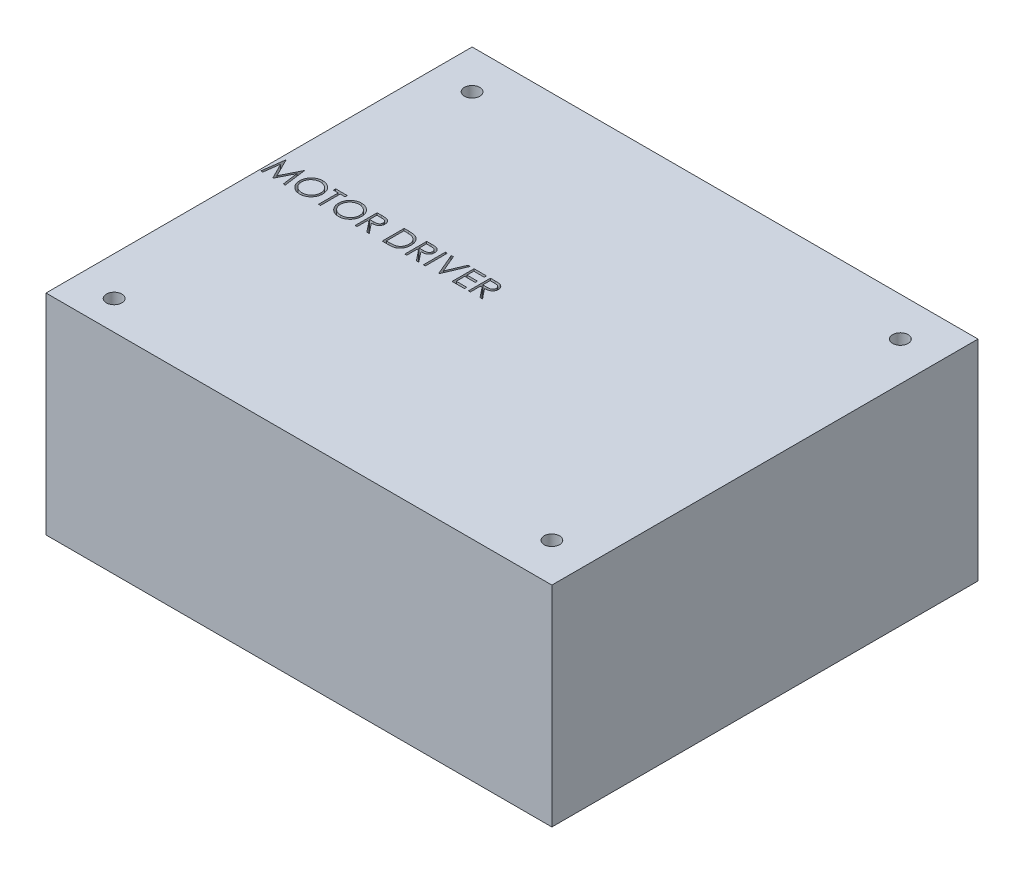
from build123d import *

# Parameters (mm, degrees)
SKETCH1_W           = 80.56
SKETCH1_H           = 67.86
BOSS_EXTRUDE1_DEPTH = 33.37
SKETCH2_R           = 1.23
CUT_EXTRUDE1_DEPTH  = 34.37
SKETCH3_W           = 0.314102564
SKETCH3_H           = 3.5
CUT_EXTRUDE2_DEPTH  = 34.37


with BuildPart() as part:
    # Sketch1 → Boss-Extrude1 (new body)
    with BuildSketch(Plane(origin=(0, 0, 0), x_dir=(1, 0, 0), z_dir=(0, 1, 0))):
        with Locations((40.28, 33.93)):
            Rectangle(SKETCH1_W, SKETCH1_H)
    extrude(amount=BOSS_EXTRUDE1_DEPTH)

    # Sketch2 → Cut-Extrude1 (cut, through all)
    with BuildSketch(Plane(origin=(0, 33.37, 0), x_dir=(1, 0, 0), z_dir=(0, 1, 0))):
        with Locations((6.18, 61.68)):
            Circle(SKETCH2_R)
        with Locations((6.18, 4.670315746)):
            Circle(SKETCH2_R)
        with Locations((74.38, 6.18)):
            Circle(SKETCH2_R)
        with Locations((74.38, 61.68)):
            Circle(SKETCH2_R)
    extrude(amount=-CUT_EXTRUDE1_DEPTH, mode=Mode.SUBTRACT)

    # Sketch3 → Cut-Extrude2 (cut, through all)
    with BuildSketch(Plane(origin=(0, 33.37, 0), x_dir=(1, 0, 0), z_dir=(0, 1, 0))):
        Polygon((0.269230769, 33.93), (0.731270032, 37.43), (0.776141827, 37.43), (2.221153846, 34.558205128), (3.661959135, 37.43), (3.706830929, 37.43), (4.173076923, 33.93), (3.858974359, 33.93), (3.522435897, 36.446326122), (2.259715545, 33.93), (2.188201122, 33.93), (0.919871795, 36.454038462), (0.585436699, 33.93), align=None)
        with BuildLine():
            add(Edge.make_bspline(
                [(6.528846154, 37.51974359), (6.59365426, 37.51810211), (6.720942727, 37.514878109), (6.908017624, 37.490199006), (7.08661272, 37.447503616), (7.258182859, 37.390640633), (7.420675835, 37.314786248), (7.575314728, 37.2231011), (7.721731601, 37.114624641), (7.857952983, 36.990195414), (7.982609933, 36.85481196), (8.092435819, 36.71033405), (8.184478113, 36.557635248), (8.2600639, 36.397174417), (8.31936251, 36.229314449), (8.360281554, 36.053160446), (8.386419704, 35.869853756), (8.389475481, 35.744826892), (8.391025641, 35.681402244)],
                knots=[0, 0, 0, 0, 0.000194393, 0.000381804, 0.00056479, 0.000744601, 0.000923091, 0.001101652, 0.001283106, 0.001468738, 0.001654324, 0.001834514, 0.002012231, 0.002188181, 0.002365797, 0.002545211, 0.002729936, 0.002920126, 0.002920126, 0.002920126, 0.002920126], degree=3))
            add(Edge.make_bspline(
                [(8.391025641, 35.681402244), (8.389475709, 35.618444797), (8.386420612, 35.494348377), (8.360251834, 35.312204933), (8.319210834, 35.137114236), (8.260614568, 34.969368583), (8.18538909, 34.80879102), (8.092733919, 34.655804066), (7.983592708, 34.510357567), (7.859385857, 34.374044902), (7.723984815, 34.249047431), (7.578754548, 34.140128556), (7.426961228, 34.046404431), (7.26665152, 33.971620757), (7.099951483, 33.911848837), (6.92536916, 33.871096207), (6.743722606, 33.844809163), (6.619851602, 33.841790647), (6.556891026, 33.84025641)],
                knots=[0, 0, 0, 0, 0.000188789, 0.000372126, 0.000550857, 0.00072758, 0.000904164, 0.001081881, 0.001263191, 0.001448823, 0.00163441, 0.001815159, 0.001992641, 0.002168591, 0.002344885, 0.002522934, 0.002705576, 0.002894365, 0.002894365, 0.002894365, 0.002894365], degree=3))
            add(Edge.make_bspline(
                [(6.556891026, 33.84025641), (6.493466707, 33.841805797), (6.368440491, 33.844860051), (6.184903455, 33.871041456), (6.008625711, 33.91198276), (5.84011136, 33.970492196), (5.679266431, 34.046109427), (5.525776348, 34.138313806), (5.380257201, 34.247720947), (5.243915454, 34.371887521), (5.119166256, 34.507059073), (5.01040688, 34.651893329), (4.918181767, 34.803548785), (4.842818435, 34.962446309), (4.783153975, 35.127817752), (4.742449157, 35.300766229), (4.716113205, 35.480305735), (4.713078359, 35.602548634), (4.711538462, 35.664575321)],
                knots=[0, 0, 0, 0, 0.00019019, 0.000374915, 0.000555011, 0.000732396, 0.00090898, 0.001087298, 0.001268608, 0.00145424, 0.001639827, 0.001819595, 0.001996712, 0.002171394, 0.002346367, 0.002523053, 0.002703612, 0.002889599, 0.002889599, 0.002889599, 0.002889599], degree=3))
            add(Edge.make_bspline(
                [(4.711538462, 35.664575321), (4.712073097, 35.70620799), (4.713135623, 35.788948113), (4.725927316, 35.911814713), (4.744489017, 36.032705371), (4.77109093, 36.151276319), (4.805882597, 36.267237304), (4.846934624, 36.381388067), (4.897074469, 36.49257179), (4.953755117, 36.601315182), (5.017016925, 36.705923088), (5.086892675, 36.804802671), (5.160928043, 36.898783668), (5.242091437, 36.985430672), (5.327707882, 37.067264328), (5.41916626, 37.143027045), (5.515908505, 37.213401996), (5.618350884, 37.276822337), (5.723969159, 37.334181472), (5.832845937, 37.383403323), (5.943502509, 37.425649384), (6.056457157, 37.459890209), (6.171409929, 37.486922245), (6.288611713, 37.505329599), (6.407969139, 37.518153917), (6.488380458, 37.519211419), (6.528846154, 37.51974359)],
                knots=[0, 0, 0, 0, 0.000124849, 0.000248123, 0.000370193, 0.00049164, 0.000612319, 0.000733199, 0.000855287, 0.000977905, 0.001100913, 0.001221706, 0.001340948, 0.001459521, 0.001577551, 0.001696047, 0.001815534, 0.001936153, 0.002057243, 0.002175846, 0.002294342, 0.002412335, 0.002529682, 0.00264829, 0.002768075, 0.00288942, 0.00288942, 0.00288942, 0.00288942], degree=3))
        make_face()
        with BuildLine():
            add(Edge.make_bspline(
                [(6.544270833, 37.160769231), (6.5110562, 37.160364341), (6.444944467, 37.159558431), (6.346659931, 37.148942715), (6.249667997, 37.133812826), (6.153948635, 37.112231305), (6.059902345, 37.082827253), (5.966652504, 37.048986345), (5.87504945, 37.007765254), (5.785395592, 36.96119255), (5.698480517, 36.909643629), (5.616467816, 36.852671862), (5.539145172, 36.791613307), (5.466701905, 36.72632547), (5.399350733, 36.656475868), (5.335766031, 36.583123432), (5.27849645, 36.504171541), (5.226010873, 36.421761134), (5.179043033, 36.335999553), (5.137277678, 36.247789691), (5.103113669, 36.156412004), (5.075251293, 36.062857846), (5.052151482, 35.967275387), (5.037517558, 35.868939538), (5.026785199, 35.768344426), (5.026025353, 35.700362572), (5.025641026, 35.665977564)],
                knots=[0, 0, 0, 0, 9.9599e-05, 0.000198245, 0.000296222, 0.00039402, 0.00049227, 0.000591646, 0.000691452, 0.000793368, 0.000894612, 0.000994383, 0.001092713, 0.00119001, 0.001286696, 0.001383657, 0.001480979, 0.001579008, 0.001676595, 0.001774142, 0.001871547, 0.001968922, 0.002066879, 0.00216624, 0.00226698, 0.002370083, 0.002370083, 0.002370083, 0.002370083], degree=3))
            add(Edge.make_bspline(
                [(5.025641026, 35.665977564), (5.026915888, 35.615415343), (5.029423935, 35.515943813), (5.051381506, 35.370175669), (5.08520348, 35.230087383), (5.135060846, 35.096445474), (5.197411461, 34.968101191), (5.274438351, 34.846193086), (5.365697437, 34.730688212), (5.469360964, 34.622392943), (5.58268367, 34.523547138), (5.7030164, 34.43678373), (5.829070008, 34.36337348), (5.96117321, 34.303568408), (6.098620749, 34.25617867), (6.2422983, 34.223700039), (6.39124876, 34.202324583), (6.492779415, 34.200271827), (6.544270833, 34.199230769)],
                knots=[0, 0, 0, 0, 0.000151605, 0.000298253, 0.000441263, 0.000583229, 0.000725274, 0.000868635, 0.001014928, 0.001166177, 0.001317744, 0.00146543, 0.001610576, 0.001754594, 0.001899821, 0.002045914, 0.002195936, 0.002350312, 0.002350312, 0.002350312, 0.002350312], degree=3))
            add(Edge.make_bspline(
                [(6.544270833, 34.199230769), (6.578880335, 34.199706274), (6.647521371, 34.200649342), (6.749616894, 34.210148018), (6.849873105, 34.225379888), (6.948149385, 34.247310543), (7.044334197, 34.27475775), (7.138829, 34.307365478), (7.23062729, 34.348046682), (7.320887128, 34.392994633), (7.40728337, 34.444234791), (7.489758902, 34.49927294), (7.566234882, 34.560241561), (7.638623953, 34.624559374), (7.706251642, 34.693523221), (7.768660626, 34.767043443), (7.825640759, 34.8455841), (7.878106405, 34.927869506), (7.924909668, 35.013865759), (7.965688767, 35.102395437), (8.000284883, 35.193240546), (8.028213388, 35.286532118), (8.050098849, 35.382092966), (8.065178769, 35.480051045), (8.075727208, 35.580210387), (8.076522285, 35.647954243), (8.076923077, 35.682103365)],
                knots=[0, 0, 0, 0, 0.000103804, 0.000205874, 0.000307314, 0.000407849, 0.000507719, 0.000607281, 0.000707445, 0.000808723, 0.000909609, 0.001008589, 0.001105934, 0.001202762, 0.001298946, 0.001395452, 0.001491794, 0.001589823, 0.001688026, 0.001785277, 0.001882027, 0.001979402, 0.0020772, 0.002175869, 0.002276609, 0.002379011, 0.002379011, 0.002379011, 0.002379011], degree=3))
            add(Edge.make_bspline(
                [(8.076923077, 35.682103365), (8.076521964, 35.71601887), (8.075726282, 35.78329652), (8.065183808, 35.882757338), (8.050082917, 35.98001055), (8.028320209, 36.074674353), (8.000270056, 36.166772878), (7.965682725, 36.256219625), (7.924897426, 36.343347821), (7.878089201, 36.427942118), (7.825473378, 36.509116855), (7.767979135, 36.586719268), (7.704613787, 36.659292009), (7.637187762, 36.728626703), (7.564016876, 36.793244593), (7.485432582, 36.853167114), (7.402388904, 36.909840388), (7.314461669, 36.96096595), (7.223717715, 37.008180182), (7.130603757, 37.048631186), (7.036174658, 37.083003305), (6.940670545, 37.11232027), (6.843287567, 37.1337283), (6.744683738, 37.14895635), (6.64499548, 37.159554736), (6.57795226, 37.160363114), (6.544270833, 37.160769231)],
                knots=[0, 0, 0, 0, 0.000101701, 0.000201743, 0.00029972, 0.000396835, 0.000492868, 0.000588308, 0.000684288, 0.000781261, 0.000878109, 0.000974304, 0.001070733, 0.001166917, 0.001264269, 0.001363274, 0.001463228, 0.001565678, 0.001668217, 0.001769947, 0.001869982, 0.001969573, 0.002069423, 0.002168785, 0.002268827, 0.002369827, 0.002369827, 0.002369827, 0.002369827], degree=3))
        make_face(mode=Mode.SUBTRACT)
        Polygon((8.705128205, 37.071025641), (8.705128205, 37.43), (10.544871795, 37.43), (10.544871795, 37.071025641), (9.782051282, 37.071025641), (9.782051282, 33.93), (9.467948718, 33.93), (9.467948718, 37.071025641), align=None)
        with BuildLine():
            add(Edge.make_bspline(
                [(12.721153846, 37.51974359), (12.785961952, 37.51810211), (12.913250419, 37.514878109), (13.100325317, 37.490199006), (13.278920412, 37.447503616), (13.450490551, 37.390640633), (13.612983527, 37.314786248), (13.76762242, 37.2231011), (13.914039294, 37.114624641), (14.050260675, 36.990195414), (14.174917626, 36.85481196), (14.284743512, 36.71033405), (14.376785806, 36.557635248), (14.452371593, 36.397174417), (14.511670202, 36.229314449), (14.552589246, 36.053160446), (14.578727396, 35.869853756), (14.581783174, 35.744826892), (14.583333333, 35.681402244)],
                knots=[0, 0, 0, 0, 0.000194393, 0.000381804, 0.00056479, 0.000744601, 0.000923091, 0.001101652, 0.001283106, 0.001468738, 0.001654324, 0.001834514, 0.002012231, 0.002188181, 0.002365797, 0.002545211, 0.002729936, 0.002920126, 0.002920126, 0.002920126, 0.002920126], degree=3))
            add(Edge.make_bspline(
                [(14.583333333, 35.681402244), (14.581783401, 35.618444797), (14.578728304, 35.494348377), (14.552559527, 35.312204933), (14.511518527, 35.137114236), (14.452922261, 34.969368583), (14.377696782, 34.80879102), (14.285041611, 34.655804066), (14.1759004, 34.510357567), (14.051693549, 34.374044902), (13.916292507, 34.249047431), (13.77106224, 34.140128556), (13.61926892, 34.046404431), (13.458959212, 33.971620757), (13.292259175, 33.911848837), (13.117676852, 33.871096207), (12.936030298, 33.844809163), (12.812159295, 33.841790647), (12.749198718, 33.84025641)],
                knots=[0, 0, 0, 0, 0.000188789, 0.000372126, 0.000550857, 0.00072758, 0.000904164, 0.001081881, 0.001263191, 0.001448823, 0.00163441, 0.001815159, 0.001992641, 0.002168591, 0.002344885, 0.002522934, 0.002705576, 0.002894365, 0.002894365, 0.002894365, 0.002894365], degree=3))
            add(Edge.make_bspline(
                [(12.749198718, 33.84025641), (12.685774399, 33.841805797), (12.560748183, 33.844860051), (12.377211148, 33.871041456), (12.200933404, 33.91198276), (12.032419053, 33.970492196), (11.871574123, 34.046109427), (11.71808404, 34.138313806), (11.572564893, 34.247720947), (11.436223147, 34.371887521), (11.311473948, 34.507059073), (11.202714573, 34.651893329), (11.110489459, 34.803548785), (11.035126127, 34.962446309), (10.975461668, 35.127817752), (10.934756849, 35.300766229), (10.908420897, 35.480305735), (10.905386051, 35.602548634), (10.903846154, 35.664575321)],
                knots=[0, 0, 0, 0, 0.00019019, 0.000374915, 0.000555011, 0.000732396, 0.00090898, 0.001087298, 0.001268608, 0.00145424, 0.001639827, 0.001819595, 0.001996712, 0.002171394, 0.002346367, 0.002523053, 0.002703612, 0.002889599, 0.002889599, 0.002889599, 0.002889599], degree=3))
            add(Edge.make_bspline(
                [(10.903846154, 35.664575321), (10.904380789, 35.70620799), (10.905443316, 35.788948113), (10.918235008, 35.911814713), (10.936796709, 36.032705371), (10.963398622, 36.151276319), (10.998190289, 36.267237304), (11.039242316, 36.381388067), (11.089382162, 36.49257179), (11.14606281, 36.601315182), (11.209324618, 36.705923088), (11.279200367, 36.804802671), (11.353235736, 36.898783668), (11.434399129, 36.985430672), (11.520015574, 37.067264328), (11.611473953, 37.143027045), (11.708216197, 37.213401996), (11.810658577, 37.276822337), (11.916276852, 37.334181472), (12.025153629, 37.383403323), (12.135810201, 37.425649384), (12.248764849, 37.459890209), (12.363717621, 37.486922245), (12.480919405, 37.505329599), (12.600276832, 37.518153917), (12.680688151, 37.519211419), (12.721153846, 37.51974359)],
                knots=[0, 0, 0, 0, 0.000124849, 0.000248123, 0.000370193, 0.00049164, 0.000612319, 0.000733199, 0.000855287, 0.000977905, 0.001100913, 0.001221706, 0.001340948, 0.001459521, 0.001577551, 0.001696047, 0.001815534, 0.001936153, 0.002057243, 0.002175846, 0.002294342, 0.002412335, 0.002529682, 0.00264829, 0.002768075, 0.00288942, 0.00288942, 0.00288942, 0.00288942], degree=3))
        make_face()
        with BuildLine():
            add(Edge.make_bspline(
                [(12.736578526, 37.160769231), (12.703363892, 37.160364341), (12.637252159, 37.159558431), (12.538967623, 37.148942715), (12.441975689, 37.133812826), (12.346256327, 37.112231305), (12.252210038, 37.082827253), (12.158960196, 37.048986345), (12.067357142, 37.007765254), (11.977703285, 36.96119255), (11.890788209, 36.909643629), (11.808775508, 36.852671862), (11.731452864, 36.791613307), (11.659009597, 36.72632547), (11.591658425, 36.656475868), (11.528073724, 36.583123432), (11.470804142, 36.504171541), (11.418318565, 36.421761134), (11.371350725, 36.335999553), (11.32958537, 36.247789691), (11.295421362, 36.156412004), (11.267558985, 36.062857846), (11.244459174, 35.967275387), (11.22982525, 35.868939538), (11.219092891, 35.768344426), (11.218333045, 35.700362572), (11.217948718, 35.665977564)],
                knots=[0, 0, 0, 0, 9.9599e-05, 0.000198245, 0.000296222, 0.00039402, 0.00049227, 0.000591646, 0.000691452, 0.000793368, 0.000894612, 0.000994383, 0.001092713, 0.00119001, 0.001286696, 0.001383657, 0.001480979, 0.001579008, 0.001676595, 0.001774142, 0.001871547, 0.001968922, 0.002066879, 0.00216624, 0.00226698, 0.002370083, 0.002370083, 0.002370083, 0.002370083], degree=3))
            add(Edge.make_bspline(
                [(11.217948718, 35.665977564), (11.21922358, 35.615415343), (11.221731628, 35.515943813), (11.243689198, 35.370175669), (11.277511172, 35.230087383), (11.327368539, 35.096445474), (11.389719153, 34.968101191), (11.466746044, 34.846193086), (11.558005129, 34.730688212), (11.661668656, 34.622392943), (11.774991362, 34.523547138), (11.895324092, 34.43678373), (12.0213777, 34.36337348), (12.153480903, 34.303568408), (12.290928442, 34.25617867), (12.434605993, 34.223700039), (12.583556452, 34.202324583), (12.685087107, 34.200271827), (12.736578526, 34.199230769)],
                knots=[0, 0, 0, 0, 0.000151605, 0.000298253, 0.000441263, 0.000583229, 0.000725274, 0.000868635, 0.001014928, 0.001166177, 0.001317744, 0.00146543, 0.001610576, 0.001754594, 0.001899821, 0.002045914, 0.002195936, 0.002350312, 0.002350312, 0.002350312, 0.002350312], degree=3))
            add(Edge.make_bspline(
                [(12.736578526, 34.199230769), (12.771188027, 34.199706274), (12.839829064, 34.200649342), (12.941924586, 34.210148018), (13.042180798, 34.225379888), (13.140457078, 34.247310543), (13.236641889, 34.27475775), (13.331136692, 34.307365478), (13.422934982, 34.348046682), (13.51319482, 34.392994633), (13.599591062, 34.444234791), (13.682066594, 34.49927294), (13.758542574, 34.560241561), (13.830931645, 34.624559374), (13.898559334, 34.693523221), (13.960968319, 34.767043443), (14.017948451, 34.8455841), (14.070414097, 34.927869506), (14.11721736, 35.013865759), (14.157996459, 35.102395437), (14.192592575, 35.193240546), (14.22052108, 35.286532118), (14.242406542, 35.382092966), (14.257486462, 35.480051045), (14.2680349, 35.580210387), (14.268829977, 35.647954243), (14.269230769, 35.682103365)],
                knots=[0, 0, 0, 0, 0.000103804, 0.000205874, 0.000307314, 0.000407849, 0.000507719, 0.000607281, 0.000707445, 0.000808723, 0.000909609, 0.001008589, 0.001105934, 0.001202762, 0.001298946, 0.001395452, 0.001491794, 0.001589823, 0.001688026, 0.001785277, 0.001882027, 0.001979402, 0.0020772, 0.002175869, 0.002276609, 0.002379011, 0.002379011, 0.002379011, 0.002379011], degree=3))
            add(Edge.make_bspline(
                [(14.269230769, 35.682103365), (14.268829656, 35.71601887), (14.268033975, 35.78329652), (14.2574915, 35.882757338), (14.24239061, 35.98001055), (14.220627902, 36.074674353), (14.192577748, 36.166772878), (14.157990418, 36.256219625), (14.117205118, 36.343347821), (14.070396894, 36.427942118), (14.01778107, 36.509116855), (13.960286827, 36.586719268), (13.896921479, 36.659292009), (13.829495454, 36.728626703), (13.756324569, 36.793244593), (13.677740275, 36.853167114), (13.594696597, 36.909840388), (13.506769361, 36.96096595), (13.416025408, 37.008180182), (13.32291145, 37.048631186), (13.22848235, 37.083003305), (13.132978238, 37.11232027), (13.035595259, 37.1337283), (12.936991431, 37.14895635), (12.837303172, 37.159554736), (12.770259952, 37.160363114), (12.736578526, 37.160769231)],
                knots=[0, 0, 0, 0, 0.000101701, 0.000201743, 0.00029972, 0.000396835, 0.000492868, 0.000588308, 0.000684288, 0.000781261, 0.000878109, 0.000974304, 0.001070733, 0.001166917, 0.001264269, 0.001363274, 0.001463228, 0.001565678, 0.001668217, 0.001769947, 0.001869982, 0.001969573, 0.002069423, 0.002168785, 0.002268827, 0.002369827, 0.002369827, 0.002369827, 0.002369827], degree=3))
        make_face(mode=Mode.SUBTRACT)
        with BuildLine():
            Line((15.301282051, 37.43), (16.001702724, 37.43))
            add(Edge.make_bspline(
                [(16.001702724, 37.43), (16.048443853, 37.429844414), (16.138191997, 37.429545672), (16.266765268, 37.427879909), (16.383592365, 37.423105553), (16.488612204, 37.41899697), (16.581822859, 37.411505028), (16.66351015, 37.404344381), (16.733297847, 37.39497072), (16.775543698, 37.386265297), (16.794671474, 37.382323718)],
                knots=[0, 0, 0, 0, 0.000140226, 0.00026925, 0.000385712, 0.000490995, 0.000584507, 0.000666202, 0.000736998, 0.000795574, 0.000795574, 0.000795574, 0.000795574], degree=3))
            add(Edge.make_bspline(
                [(16.794671474, 37.382323718), (16.820278098, 37.375996953), (16.870945088, 37.363478389), (16.943895154, 37.337018788), (17.013409478, 37.306399163), (17.079199302, 37.270435443), (17.140935093, 37.228860663), (17.199253404, 37.182392541), (17.254418868, 37.131285335), (17.304200498, 37.074250494), (17.35113955, 37.014413984), (17.390728176, 36.949710227), (17.424854656, 36.8820487), (17.452025173, 36.810741282), (17.473903146, 36.73647951), (17.489329386, 36.658590713), (17.498580573, 36.577429738), (17.499522429, 36.52207183), (17.5, 36.494002404)],
                knots=[0, 0, 0, 0, 7.9081e-05, 0.000156475, 0.000232432, 0.000306798, 0.00038108, 0.000455429, 0.000530331, 0.000606314, 0.000682321, 0.000758201, 0.000833453, 0.000909362, 0.000986794, 0.001065445, 0.001147284, 0.001231465, 0.001231465, 0.001231465, 0.001231465], degree=3))
            add(Edge.make_bspline(
                [(17.5, 36.494002404), (17.498531002, 36.447367299), (17.495664606, 36.356370131), (17.468939502, 36.22430925), (17.425162983, 36.101119935), (17.364839694, 35.986957297), (17.288020218, 35.884046652), (17.195695427, 35.793656197), (17.087813815, 35.718016284), (16.987384499, 35.665563479), (16.8986703, 35.631970571), (16.825636987, 35.608334212), (16.745970009, 35.590072247), (16.660432675, 35.573712115), (16.568669019, 35.56136042), (16.47089898, 35.552313826), (16.367052828, 35.546659777), (16.295713759, 35.545817772), (16.259014423, 35.545384615)],
                knots=[0, 0, 0, 0, 0.000139777, 0.000272741, 0.000402249, 0.000530843, 0.000658588, 0.000786009, 0.000916741, 0.001052522, 0.001124656, 0.001201155, 0.001282612, 0.001369656, 0.001462366, 0.001560247, 0.001664165, 0.001774261, 0.001774261, 0.001774261, 0.001774261], degree=3))
            Line((16.259014423, 35.545384615), (17.544871795, 33.93))
            Line((17.544871795, 33.93), (17.156450321, 33.93))
            Line((17.156450321, 33.93), (15.870592949, 35.545384615))
            Line((15.870592949, 35.545384615), (15.615384615, 35.545384615))
            Line((15.615384615, 35.545384615), (15.615384615, 33.93))
            Line((15.615384615, 33.93), (15.301282051, 33.93))
            Line((15.301282051, 33.93), (15.301282051, 37.43))
        make_face()
        with BuildLine():
            Line((15.615384615, 37.071025641), (15.615384615, 35.904358974))
            Line((15.615384615, 35.904358974), (16.256209936, 35.899451122))
            add(Edge.make_bspline(
                [(16.256209936, 35.899451122), (16.286129975, 35.899437885), (16.344123532, 35.899412229), (16.428024197, 35.903406005), (16.506144308, 35.907949323), (16.578185061, 35.914898669), (16.644178636, 35.92385474), (16.704092049, 35.935057725), (16.758023101, 35.948109787), (16.820921639, 35.968311413), (16.891158171, 36.000317431), (16.967489631, 36.04688293), (17.032491968, 36.105452049), (17.087409831, 36.172425505), (17.131539262, 36.246061754), (17.162651317, 36.325478123), (17.182393759, 36.408669721), (17.184722304, 36.465847829), (17.185897436, 36.494703526)],
                knots=[0, 0, 0, 0, 8.9746e-05, 0.000173954, 0.000251933, 0.000324488, 0.000391021, 0.000451663, 0.000507268, 0.000557378, 0.000649639, 0.000738152, 0.000824558, 0.000910739, 0.000997194, 0.001080909, 0.00116578, 0.001252248, 0.001252248, 0.001252248, 0.001252248], degree=3))
            add(Edge.make_bspline(
                [(17.185897436, 36.494703526), (17.184695315, 36.522850099), (17.182313149, 36.578626338), (17.162864381, 36.660282248), (17.129975, 36.737349198), (17.085652762, 36.809513683), (17.031653607, 36.875019419), (16.968335794, 36.931066572), (16.897430599, 36.977316037), (16.8311594, 37.006870418), (16.771925188, 37.024990271), (16.720495528, 37.037741435), (16.66238405, 37.047985904), (16.597308592, 37.056193964), (16.525546961, 37.063248909), (16.44673631, 37.068000687), (16.361399529, 37.070814551), (16.302252598, 37.07095364), (16.271634615, 37.071025641)],
                knots=[0, 0, 0, 0, 8.4371e-05, 0.000167192, 0.000250141, 0.000334794, 0.000420435, 0.000503871, 0.000587493, 0.000673488, 0.0007205, 0.000773215, 0.000832351, 0.0008974, 0.000969955, 0.001048634, 0.001134217, 0.001226067, 0.001226067, 0.001226067, 0.001226067], degree=3))
            Line((16.271634615, 37.071025641), (15.615384615, 37.071025641))
        make_face(mode=Mode.SUBTRACT)
        with BuildLine():
            Line((19.608974359, 33.93), (19.608974359, 37.43))
            Line((19.608974359, 37.43), (20.315705128, 37.43))
            add(Edge.make_bspline(
                [(20.315705128, 37.43), (20.377174116, 37.42955743), (20.495931882, 37.428702387), (20.667544329, 37.423280996), (20.826328092, 37.41369053), (20.971760951, 37.399721004), (21.104242163, 37.38256797), (21.223400771, 37.361067566), (21.329852914, 37.335679396), (21.395322354, 37.314033945), (21.426282051, 37.303798077)],
                knots=[0, 0, 0, 0, 0.000184407, 0.000356273, 0.000515031, 0.000661537, 0.000794508, 0.000915664, 0.001024665, 0.001122454, 0.001122454, 0.001122454, 0.001122454], degree=3))
            add(Edge.make_bspline(
                [(21.426282051, 37.303798077), (21.466776791, 37.288367371), (21.546847983, 37.257855877), (21.660855105, 37.200299576), (21.768180468, 37.135086474), (21.869399613, 37.062130611), (21.96220044, 36.979366263), (22.050208336, 36.890309177), (22.12982306, 36.791720837), (22.202731356, 36.685645849), (22.268467016, 36.573333797), (22.325606174, 36.454998688), (22.373060167, 36.33124148), (22.412453393, 36.202406332), (22.443499851, 36.068209954), (22.464681783, 35.928496088), (22.478652773, 35.783816899), (22.480056824, 35.685642435), (22.480769231, 35.635829327)],
                knots=[0, 0, 0, 0, 0.000129935, 0.000256923, 0.000382457, 0.000506429, 0.000630624, 0.000755071, 0.000881654, 0.001010204, 0.001140916, 0.00127168, 0.001403968, 0.001538146, 0.001675568, 0.001816774, 0.001961818, 0.002111216, 0.002111216, 0.002111216, 0.002111216], degree=3))
            add(Edge.make_bspline(
                [(22.480769231, 35.635829327), (22.480140263, 35.592568088), (22.478900817, 35.507317299), (22.467771501, 35.381676404), (22.451595181, 35.259762833), (22.426550983, 35.142157132), (22.39614847, 35.027828915), (22.357184319, 34.91799667), (22.312548823, 34.811652861), (22.260498944, 34.710235385), (22.203357559, 34.614152013), (22.142035816, 34.523576485), (22.07659912, 34.439801263), (22.006423487, 34.362572651), (21.932415771, 34.292007072), (21.85409144, 34.227515057), (21.77124839, 34.170358502), (21.684257667, 34.118291394), (21.590581538, 34.072871038), (21.488445672, 34.034441029), (21.377414494, 34.002594413), (21.257760537, 33.976023517), (21.129277059, 33.954946215), (20.991838093, 33.940819822), (20.845654803, 33.93126689), (20.745275538, 33.930430496), (20.693609776, 33.93)],
                knots=[0, 0, 0, 0, 0.000129755, 0.000255696, 0.000378151, 0.000498469, 0.000616165, 0.000732801, 0.000847787, 0.000961923, 0.00107447, 0.001182981, 0.001289856, 0.001393094, 0.001495748, 0.001596383, 0.00169713, 0.001797413, 0.001900265, 0.002008995, 0.002124372, 0.002246504, 0.002376522, 0.002514729, 0.002660846, 0.00281582, 0.00281582, 0.00281582, 0.00281582], degree=3))
            Line((20.693609776, 33.93), (19.608974359, 33.93))
        make_face()
        with BuildLine():
            Line((19.923076923, 34.288974359), (20.324819712, 34.288974359))
            add(Edge.make_bspline(
                [(20.324819712, 34.288974359), (20.382548082, 34.289222455), (20.493580881, 34.289699636), (20.653238878, 34.293886839), (20.799118274, 34.300728776), (20.931239784, 34.310303854), (21.049528808, 34.322972469), (21.154232558, 34.337097372), (21.245007816, 34.354694823), (21.299937253, 34.370645782), (21.325320513, 34.378016827)],
                knots=[0, 0, 0, 0, 0.000173183, 0.000333094, 0.000479096, 0.000611272, 0.000730431, 0.000835931, 0.000928194, 0.001007458, 0.001007458, 0.001007458, 0.001007458], degree=3))
            add(Edge.make_bspline(
                [(21.325320513, 34.378016827), (21.357268875, 34.389268385), (21.420402513, 34.411502758), (21.511283598, 34.45206042), (21.596040603, 34.500102489), (21.676150628, 34.553504763), (21.750477284, 34.614150765), (21.8199014, 34.680721754), (21.884283201, 34.753556529), (21.942957509, 34.832564691), (21.995465813, 34.917254486), (22.040937043, 35.00679332), (22.080788574, 35.10020013), (22.112067167, 35.198909289), (22.136582751, 35.302038347), (22.153947439, 35.409594561), (22.164762164, 35.521557843), (22.166023612, 35.597709967), (22.166666667, 35.636530449)],
                knots=[0, 0, 0, 0, 0.000101593, 0.000200759, 0.000298073, 0.000393552, 0.000489254, 0.000585454, 0.000681817, 0.000780535, 0.000880346, 0.000980374, 0.001081551, 0.001184655, 0.001290601, 0.001399295, 0.001511268, 0.001627707, 0.001627707, 0.001627707, 0.001627707], degree=3))
            add(Edge.make_bspline(
                [(22.166666667, 35.636530449), (22.166153379, 35.677463929), (22.165145022, 35.757878113), (22.152470711, 35.875868809), (22.133949156, 35.989349459), (22.10716547, 36.098327655), (22.073034591, 36.203016007), (22.030439949, 36.302835517), (21.98177333, 36.398840386), (21.923869993, 36.488814752), (21.8604544, 36.573907861), (21.79007652, 36.651862776), (21.713854482, 36.722857077), (21.632619632, 36.787996389), (21.544082533, 36.844660065), (21.450328842, 36.895346746), (21.349983171, 36.938362638), (21.280170475, 36.9612415), (21.244691506, 36.97286859)],
                knots=[0, 0, 0, 0, 0.000122746, 0.000241136, 0.000355593, 0.000467485, 0.000577457, 0.000685538, 0.00079278, 0.000899951, 0.001006101, 0.00111085, 0.001214524, 0.001318328, 0.001422759, 0.001529413, 0.00163777, 0.001749741, 0.001749741, 0.001749741, 0.001749741], degree=3))
            add(Edge.make_bspline(
                [(21.244691506, 36.97286859), (21.21534036, 36.980985018), (21.15293177, 36.99824277), (21.051092306, 37.017068143), (20.936477156, 37.033672642), (20.808577455, 37.047730681), (20.667538996, 37.057818002), (20.513253308, 37.065389317), (20.345653704, 37.070495949), (20.22947117, 37.070844657), (20.169170673, 37.071025641)],
                knots=[0, 0, 0, 0, 9.1321e-05, 0.000194173, 0.000310382, 0.000438754, 0.000580072, 0.000734511, 0.000902151, 0.001083046, 0.001083046, 0.001083046, 0.001083046], degree=3))
            Line((20.169170673, 37.071025641), (19.923076923, 37.071025641))
            Line((19.923076923, 37.071025641), (19.923076923, 34.288974359))
        make_face(mode=Mode.SUBTRACT)
        with BuildLine():
            Line((23.198717949, 37.43), (23.899138622, 37.43))
            add(Edge.make_bspline(
                [(23.899138622, 37.43), (23.94587975, 37.429844414), (24.035627895, 37.429545672), (24.164201165, 37.427879909), (24.281028262, 37.423105553), (24.386048101, 37.41899697), (24.479258756, 37.411505028), (24.560946047, 37.404344381), (24.630733745, 37.39497072), (24.672979596, 37.386265297), (24.692107372, 37.382323718)],
                knots=[0, 0, 0, 0, 0.000140226, 0.00026925, 0.000385712, 0.000490995, 0.000584507, 0.000666202, 0.000736998, 0.000795574, 0.000795574, 0.000795574, 0.000795574], degree=3))
            add(Edge.make_bspline(
                [(24.692107372, 37.382323718), (24.717713996, 37.375996953), (24.768380985, 37.363478389), (24.841331051, 37.337018788), (24.910845375, 37.306399163), (24.9766352, 37.270435443), (25.038370991, 37.228860663), (25.096689302, 37.182392541), (25.151854765, 37.131285335), (25.201636395, 37.074250494), (25.248575447, 37.014413984), (25.288164073, 36.949710227), (25.322290553, 36.8820487), (25.34946107, 36.810741282), (25.371339044, 36.73647951), (25.386765283, 36.658590713), (25.396016471, 36.577429738), (25.396958326, 36.52207183), (25.397435897, 36.494002404)],
                knots=[0, 0, 0, 0, 7.9081e-05, 0.000156475, 0.000232432, 0.000306798, 0.00038108, 0.000455429, 0.000530331, 0.000606314, 0.000682321, 0.000758201, 0.000833453, 0.000909362, 0.000986794, 0.001065445, 0.001147284, 0.001231465, 0.001231465, 0.001231465, 0.001231465], degree=3))
            add(Edge.make_bspline(
                [(25.397435897, 36.494002404), (25.395966899, 36.447367299), (25.393100504, 36.356370131), (25.3663754, 36.22430925), (25.32259888, 36.101119935), (25.262275591, 35.986957297), (25.185456115, 35.884046652), (25.093131324, 35.793656197), (24.985249713, 35.718016284), (24.884820397, 35.665563479), (24.796106197, 35.631970571), (24.723072884, 35.608334212), (24.643405907, 35.590072247), (24.557868572, 35.573712115), (24.466104917, 35.56136042), (24.368334877, 35.552313826), (24.264488726, 35.546659777), (24.193149656, 35.545817772), (24.156450321, 35.545384615)],
                knots=[0, 0, 0, 0, 0.000139777, 0.000272741, 0.000402249, 0.000530843, 0.000658588, 0.000786009, 0.000916741, 0.001052522, 0.001124656, 0.001201155, 0.001282612, 0.001369656, 0.001462366, 0.001560247, 0.001664165, 0.001774261, 0.001774261, 0.001774261, 0.001774261], degree=3))
            Line((24.156450321, 35.545384615), (25.442307692, 33.93))
            Line((25.442307692, 33.93), (25.053886218, 33.93))
            Line((25.053886218, 33.93), (23.768028846, 35.545384615))
            Line((23.768028846, 35.545384615), (23.512820513, 35.545384615))
            Line((23.512820513, 35.545384615), (23.512820513, 33.93))
            Line((23.512820513, 33.93), (23.198717949, 33.93))
            Line((23.198717949, 33.93), (23.198717949, 37.43))
        make_face()
        with BuildLine():
            Line((23.512820513, 37.071025641), (23.512820513, 35.904358974))
            Line((23.512820513, 35.904358974), (24.153645833, 35.899451122))
            add(Edge.make_bspline(
                [(24.153645833, 35.899451122), (24.183565872, 35.899437885), (24.241559429, 35.899412229), (24.325460094, 35.903406005), (24.403580206, 35.907949323), (24.475620958, 35.914898669), (24.541614533, 35.92385474), (24.601527947, 35.935057725), (24.655458998, 35.948109787), (24.718357537, 35.968311413), (24.788594068, 36.000317431), (24.864925528, 36.04688293), (24.929927866, 36.105452049), (24.984845728, 36.172425505), (25.02897516, 36.246061754), (25.060087214, 36.325478123), (25.079829656, 36.408669721), (25.082158202, 36.465847829), (25.083333333, 36.494703526)],
                knots=[0, 0, 0, 0, 8.9746e-05, 0.000173954, 0.000251933, 0.000324488, 0.000391021, 0.000451663, 0.000507268, 0.000557378, 0.000649639, 0.000738152, 0.000824558, 0.000910739, 0.000997194, 0.001080909, 0.00116578, 0.001252248, 0.001252248, 0.001252248, 0.001252248], degree=3))
            add(Edge.make_bspline(
                [(25.083333333, 36.494703526), (25.082131212, 36.522850099), (25.079749047, 36.578626338), (25.060300278, 36.660282248), (25.027410897, 36.737349198), (24.983088659, 36.809513683), (24.929089504, 36.875019419), (24.865771691, 36.931066572), (24.794866496, 36.977316037), (24.728595298, 37.006870418), (24.669361085, 37.024990271), (24.617931425, 37.037741435), (24.559819948, 37.047985904), (24.494744489, 37.056193964), (24.422982858, 37.063248909), (24.344172207, 37.068000687), (24.258835427, 37.070814551), (24.199688496, 37.07095364), (24.169070513, 37.071025641)],
                knots=[0, 0, 0, 0, 8.4371e-05, 0.000167192, 0.000250141, 0.000334794, 0.000420435, 0.000503871, 0.000587493, 0.000673488, 0.0007205, 0.000773215, 0.000832351, 0.0008974, 0.000969955, 0.001048634, 0.001134217, 0.001226067, 0.001226067, 0.001226067, 0.001226067], degree=3))
            Line((24.169070513, 37.071025641), (23.512820513, 37.071025641))
        make_face(mode=Mode.SUBTRACT)
        with Locations((26.317307692, 35.68)):
            Rectangle(SKETCH3_W, SKETCH3_H)
        Polygon((27.102564103, 37.43), (27.439102564, 37.43), (28.605068109, 34.673890224), (29.771734776, 37.43), (30.108974359, 37.43), (28.628205128, 33.93), (28.583333333, 33.93), align=None)
        Polygon((30.737179487, 37.43), (32.711538462, 37.43), (32.711538462, 37.071025641), (31.051282051, 37.071025641), (31.051282051, 35.994102564), (32.711538462, 35.994102564), (32.711538462, 35.635128205), (31.051282051, 35.635128205), (31.051282051, 34.288974359), (32.711538462, 34.288974359), (32.711538462, 33.93), (30.737179487, 33.93), align=None)
        with BuildLine():
            Line((33.33974359, 37.43), (34.040164263, 37.43))
            add(Edge.make_bspline(
                [(34.040164263, 37.43), (34.086905391, 37.429844414), (34.176653536, 37.429545672), (34.305226806, 37.427879909), (34.422053903, 37.423105553), (34.527073742, 37.41899697), (34.620284397, 37.411505028), (34.701971688, 37.404344381), (34.771759386, 37.39497072), (34.814005237, 37.386265297), (34.833133013, 37.382323718)],
                knots=[0, 0, 0, 0, 0.000140226, 0.00026925, 0.000385712, 0.000490995, 0.000584507, 0.000666202, 0.000736998, 0.000795574, 0.000795574, 0.000795574, 0.000795574], degree=3))
            add(Edge.make_bspline(
                [(34.833133013, 37.382323718), (34.858739637, 37.375996953), (34.909406626, 37.363478389), (34.982356692, 37.337018788), (35.051871016, 37.306399163), (35.117660841, 37.270435443), (35.179396632, 37.228860663), (35.237714943, 37.182392541), (35.292880406, 37.131285335), (35.342662036, 37.074250494), (35.389601088, 37.014413984), (35.429189714, 36.949710227), (35.463316194, 36.8820487), (35.490486711, 36.810741282), (35.512364685, 36.73647951), (35.527790924, 36.658590713), (35.537042112, 36.577429738), (35.537983967, 36.52207183), (35.538461538, 36.494002404)],
                knots=[0, 0, 0, 0, 7.9081e-05, 0.000156475, 0.000232432, 0.000306798, 0.00038108, 0.000455429, 0.000530331, 0.000606314, 0.000682321, 0.000758201, 0.000833453, 0.000909362, 0.000986794, 0.001065445, 0.001147284, 0.001231465, 0.001231465, 0.001231465, 0.001231465], degree=3))
            add(Edge.make_bspline(
                [(35.538461538, 36.494002404), (35.53699254, 36.447367299), (35.534126145, 36.356370131), (35.507401041, 36.22430925), (35.463624521, 36.101119935), (35.403301232, 35.986957297), (35.326481756, 35.884046652), (35.234156965, 35.793656197), (35.126275354, 35.718016284), (35.025846038, 35.665563479), (34.937131838, 35.631970571), (34.864098525, 35.608334212), (34.784431548, 35.590072247), (34.698894213, 35.573712115), (34.607130558, 35.56136042), (34.509360518, 35.552313826), (34.405514367, 35.546659777), (34.334175297, 35.545817772), (34.297475962, 35.545384615)],
                knots=[0, 0, 0, 0, 0.000139777, 0.000272741, 0.000402249, 0.000530843, 0.000658588, 0.000786009, 0.000916741, 0.001052522, 0.001124656, 0.001201155, 0.001282612, 0.001369656, 0.001462366, 0.001560247, 0.001664165, 0.001774261, 0.001774261, 0.001774261, 0.001774261], degree=3))
            Line((34.297475962, 35.545384615), (35.583333333, 33.93))
            Line((35.583333333, 33.93), (35.194911859, 33.93))
            Line((35.194911859, 33.93), (33.909054487, 35.545384615))
            Line((33.909054487, 35.545384615), (33.653846154, 35.545384615))
            Line((33.653846154, 35.545384615), (33.653846154, 33.93))
            Line((33.653846154, 33.93), (33.33974359, 33.93))
            Line((33.33974359, 33.93), (33.33974359, 37.43))
        make_face()
        with BuildLine():
            Line((33.653846154, 37.071025641), (33.653846154, 35.904358974))
            Line((33.653846154, 35.904358974), (34.294671474, 35.899451122))
            add(Edge.make_bspline(
                [(34.294671474, 35.899451122), (34.324591513, 35.899437885), (34.38258507, 35.899412229), (34.466485735, 35.903406005), (34.544605847, 35.907949323), (34.616646599, 35.914898669), (34.682640174, 35.92385474), (34.742553588, 35.935057725), (34.79648464, 35.948109787), (34.859383178, 35.968311413), (34.929619709, 36.000317431), (35.005951169, 36.04688293), (35.070953507, 36.105452049), (35.125871369, 36.172425505), (35.170000801, 36.246061754), (35.201112855, 36.325478123), (35.220855297, 36.408669721), (35.223183843, 36.465847829), (35.224358974, 36.494703526)],
                knots=[0, 0, 0, 0, 8.9746e-05, 0.000173954, 0.000251933, 0.000324488, 0.000391021, 0.000451663, 0.000507268, 0.000557378, 0.000649639, 0.000738152, 0.000824558, 0.000910739, 0.000997194, 0.001080909, 0.00116578, 0.001252248, 0.001252248, 0.001252248, 0.001252248], degree=3))
            add(Edge.make_bspline(
                [(35.224358974, 36.494703526), (35.223156853, 36.522850099), (35.220774688, 36.578626338), (35.201325919, 36.660282248), (35.168436538, 36.737349198), (35.1241143, 36.809513683), (35.070115145, 36.875019419), (35.006797332, 36.931066572), (34.935892137, 36.977316037), (34.869620939, 37.006870418), (34.810386726, 37.024990271), (34.758957066, 37.037741435), (34.700845589, 37.047985904), (34.63577013, 37.056193964), (34.564008499, 37.063248909), (34.485197848, 37.068000687), (34.399861068, 37.070814551), (34.340714137, 37.07095364), (34.310096154, 37.071025641)],
                knots=[0, 0, 0, 0, 8.4371e-05, 0.000167192, 0.000250141, 0.000334794, 0.000420435, 0.000503871, 0.000587493, 0.000673488, 0.0007205, 0.000773215, 0.000832351, 0.0008974, 0.000969955, 0.001048634, 0.001134217, 0.001226067, 0.001226067, 0.001226067, 0.001226067], degree=3))
            Line((34.310096154, 37.071025641), (33.653846154, 37.071025641))
        make_face(mode=Mode.SUBTRACT)
    extrude(amount=-CUT_EXTRUDE2_DEPTH, mode=Mode.SUBTRACT)


solid = part.part
